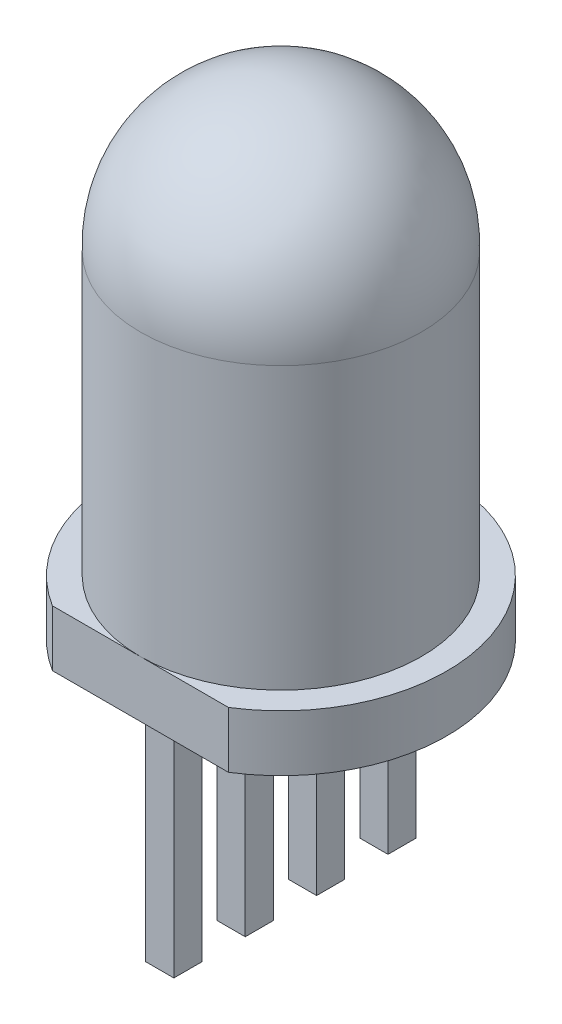
from build123d import *

# Parameters (mm, degrees)
SKETCH1_R           = 2.5
BOSS_EXTRUDE1_DEPTH = 6
SKETCH2_R           = 2.95
BOSS_EXTRUDE2_DEPTH = 1
DOME1_FACE_RADIUS   = 2.5
DOME1_HEIGHT        = 2.6
CUT_EXTRUDE1_REACH  = 10.6
SKETCH3_W           = 4.756042082
SKETCH3_H           = 0.515985698
SKETCH4_W           = 0.5
SKETCH4_H           = 0.5
BOSS_EXTRUDE3_DEPTH = 4


with BuildPart() as part:
    # Sketch1 → Boss-Extrude1 (new body)
    with BuildSketch(Plane(origin=(0, 0, 0), x_dir=(1, 0, 0), z_dir=(0, 1, 0))):
        Circle(SKETCH1_R)
    extrude(amount=BOSS_EXTRUDE1_DEPTH)

    # Sketch2 → Boss-Extrude2 (add)
    with BuildSketch(Plane(origin=(0, 0, 0), x_dir=(1, 0, 0), z_dir=(0, 1, 0))):
        Circle(SKETCH2_R)
    extrude(amount=BOSS_EXTRUDE2_DEPTH)

    # Dome1: a dome of height H over a round flat face of radius A is a cap of a sphere of radius (A * A + H * H) / (2 * H)
    dome1_r = (DOME1_FACE_RADIUS * DOME1_FACE_RADIUS + DOME1_HEIGHT * DOME1_HEIGHT) / (2 * DOME1_HEIGHT)
    dome1_base = Plane((0, 6, 0), z_dir=(0, 1, 0))
    with Locations(dome1_base.offset(DOME1_HEIGHT - dome1_r)):
        dome1_ball = Sphere(dome1_r, mode=Mode.PRIVATE)
    add(split(dome1_ball, bisect_by=dome1_base, keep=Keep.TOP, mode=Mode.PRIVATE))

    # Sketch3 → Cut-Extrude1 (cut, up to next)
    with BuildSketch(Plane.XZ, mode=Mode.PRIVATE) as cut_extrude1_sk1:
        with Locations((0.213124527, 2.757992849)):
            Rectangle(SKETCH3_W, SKETCH3_H)
    cut_extrude1_tool1 = extrude(cut_extrude1_sk1.sketch, amount=-CUT_EXTRUDE1_REACH, mode=Mode.PRIVATE) & part.part
    add(cut_extrude1_tool1.solids().sort_by_distance((0.213125, 0, 2.757993))[0], mode=Mode.SUBTRACT)

    # Sketch4 → Boss-Extrude3 (add)
    with BuildSketch(Plane.XZ):
        with Locations((0, 1.905)):
            Rectangle(SKETCH4_W, SKETCH4_H)
        with Locations((0, 0.635)):
            Rectangle(SKETCH4_W, SKETCH4_H)
        with Locations((0, -0.635)):
            Rectangle(SKETCH4_W, SKETCH4_H)
        with Locations((0, -1.905)):
            Rectangle(SKETCH4_W, SKETCH4_H)
    extrude(amount=BOSS_EXTRUDE3_DEPTH)


solid = part.part
